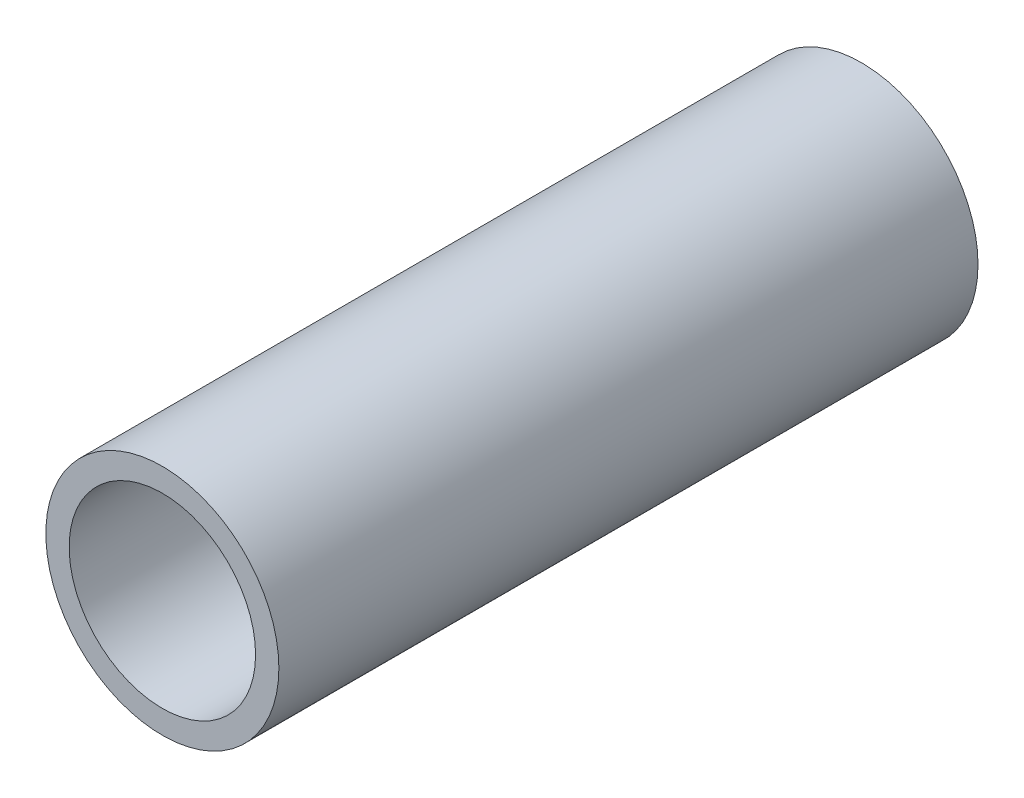
from build123d import *

# Parameters (mm, degrees)
SKETCH1_R           = 1.25
SKETCH1_R_2         = 1
BOSS_EXTRUDE1_DEPTH = 7.5


with BuildPart() as part:
    # Sketch1 → Boss-Extrude1 (new body)
    with BuildSketch(Plane.XY):
        Circle(SKETCH1_R)
        Circle(SKETCH1_R_2, mode=Mode.SUBTRACT)
    extrude(amount=BOSS_EXTRUDE1_DEPTH)


solid = part.part
